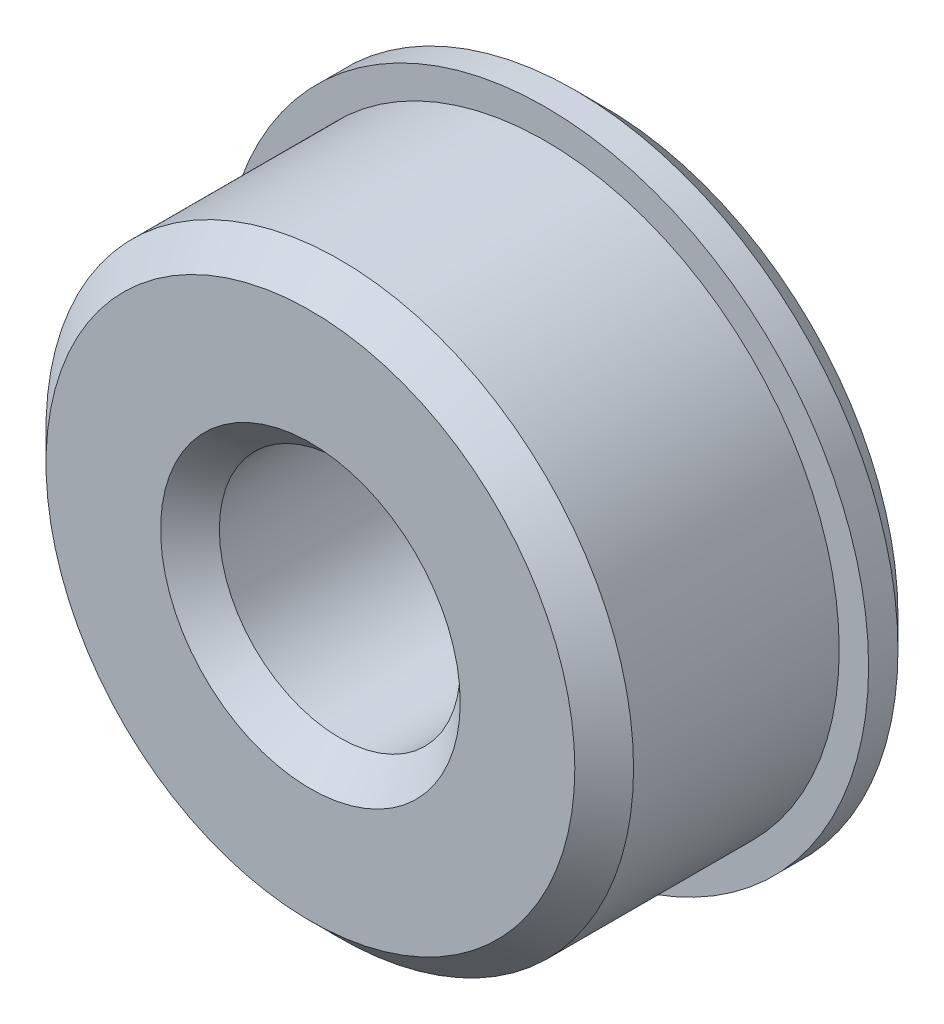
from build123d import *

# Parameters (mm, degrees)
SKETCH1_R           = 5
BOSS_EXTRUDE1_DEPTH = 4
SKETCH2_R           = 5.5
BOSS_EXTRUDE2_DEPTH = 1
SKETCH3_R           = 2.05
CUT_EXTRUDE1_DEPTH  = 6
CHAMFER1_SIZE       = 0.5


with BuildPart() as part:
    # Sketch1 → Boss-Extrude1 (new body)
    with BuildSketch(Plane.XY):
        Circle(SKETCH1_R)
    extrude(amount=BOSS_EXTRUDE1_DEPTH)

    # Sketch2 → Boss-Extrude2 (add)
    with BuildSketch(Plane.XY):
        Circle(SKETCH2_R)
    extrude(amount=-BOSS_EXTRUDE2_DEPTH)

    # Sketch3 → Cut-Extrude1 (cut, through all)
    with BuildSketch(Plane.XY.offset(4)):
        Circle(SKETCH3_R)
    extrude(amount=-CUT_EXTRUDE1_DEPTH, mode=Mode.SUBTRACT)

    # Chamfer1
    chamfer1_edges = [part.edges().sort_by_distance(p)[0] for p in [
        (-2.05, 0, -1),
        (-2.05, 0, 4),
        (-5, 0, 4),
        (-5.5, 0, -1),
    ]]
    chamfer(chamfer1_edges, length=CHAMFER1_SIZE)


solid = part.part
